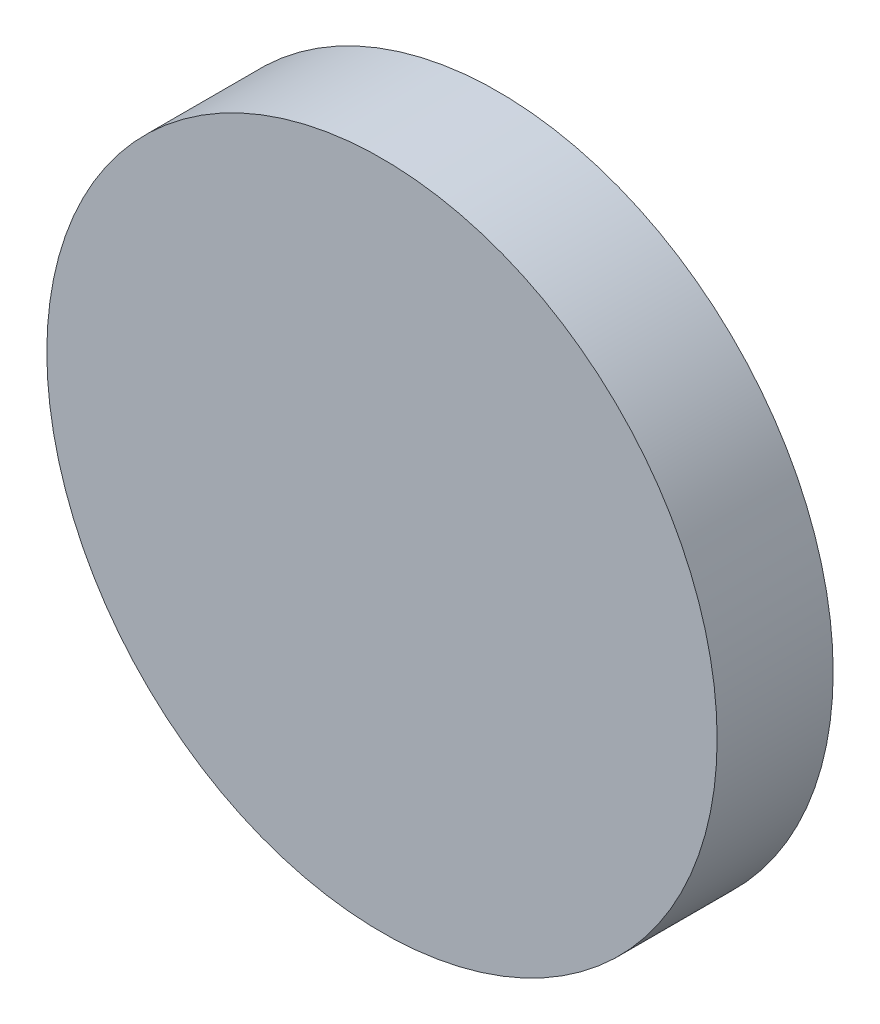
from build123d import *

# Parameters (mm, degrees)
SKETCH1_R           = 65
BOSS_EXTRUDE1_DEPTH = 22.5
SCALE1_SCALE        = 50


with BuildPart() as part:
    # Sketch1 → Boss-Extrude1 (new body)
    with BuildSketch(Plane.XY):
        Circle(SKETCH1_R)
    extrude(amount=BOSS_EXTRUDE1_DEPTH)


with BuildPart() as part_1:
    # Scale1: scaled about (0, 0, 11.25)
    add(part.part.scale(SCALE1_SCALE).moved(Location((0, 0, -551.25))))


solid = part_1.part
